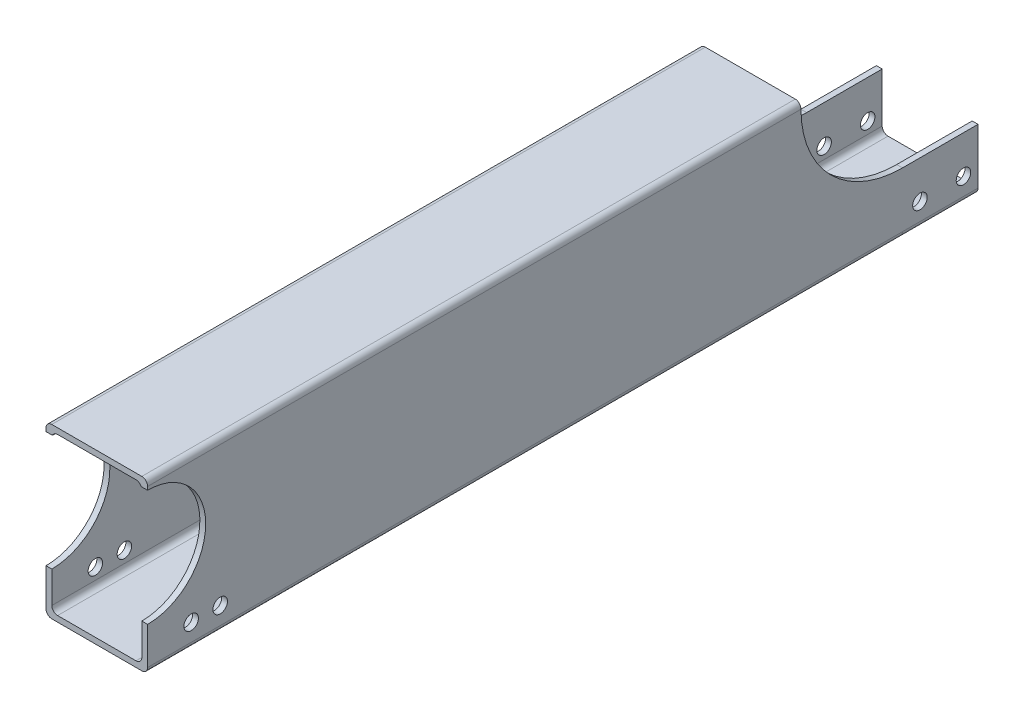
from build123d import *

# Parameters (mm, degrees)
SKETCH1_W      = 35
SKETCH1_H      = 58
SKETCH1_W_2    = 31
SKETCH1_H_2    = 54
EXTRUDE1_DEPTH = 260
FILLET1_R      = 2
SKETCH2_R      = 2.5
EXTRUDE2_DEPTH = 203.8
SKETCH3_R      = 2.5
EXTRUDE3_DEPTH = 10
EXTRUDE5_DEPTH = 26
FILLET6_R      = 2
FILLET7_R      = 2
FILLET8_R      = 2
FILLET9_R      = 2
SKETCH7_R      = 2.5
EXTRUDE6_DEPTH = 36
SKETCH8_R      = 20
SKETCH8_R_2    = 34.977592073
EXTRUDE7_DEPTH = 36


with BuildPart() as part:
    # Sketch1 → Extrude1 (new body)
    with BuildSketch(Plane.XY):
        with Locations((7.633211381, 3.238015245)):
            Rectangle(SKETCH1_W, SKETCH1_H)
        with Locations((7.633211381, 3.238015245)):
            Rectangle(SKETCH1_W_2, SKETCH1_H_2, mode=Mode.SUBTRACT)
    extrude(amount=EXTRUDE1_DEPTH)

    # Fillet1
    fillet1_edges = [part.edges().sort_by_distance(p)[0] for p in [
        (-7.866788619, 30.238015245, 130),
        (-7.866788619, -23.761984755, 130),
        (23.133211381, -23.761984755, 130),
        (23.133211381, 30.238015245, 130),
        (-9.866788619, 32.238015245, 130),
        (25.133211381, 32.238015245, 130),
        (25.133211381, -25.761984755, 130),
        (-9.866788619, -25.761984755, 130),
    ]]
    fillet(fillet1_edges, radius=FILLET1_R)

    # Sketch2 → Extrude2 (cut)
    with BuildSketch(Plane.ZY.offset(9.866788619)):
        with Locations((245, -17.761984755)):
            Circle(SKETCH2_R)
        with Locations((235, -17.761984755)):
            Circle(SKETCH2_R)
    extrude(amount=-EXTRUDE2_DEPTH, mode=Mode.SUBTRACT)

    # Sketch3 → Extrude3 (cut)
    with BuildSketch(Plane.ZY.offset(9.866788619)):
        with Locations((199, -17.761984755)):
            Circle(SKETCH3_R)
    extrude(amount=-EXTRUDE3_DEPTH, mode=Mode.SUBTRACT)

    # Sketch5 → Extrude5 (add)
    with BuildSketch(Plane(origin=(0, 0, 0), x_dir=(-1, 0, 0), z_dir=(0, 0, -1))):
        Polygon((-25.133211381, -4.739576828), (-25.133211381, -23.761984755), (-25.133211381, -25.761984755), (7.866788619, -25.761984755), (9.866788619, -25.761984755), (9.866788619, -4.739576828), (7.866788619, -4.739576828), (7.866788619, -21.761984755), (7.866788619, -23.761984755), (-23.133211381, -23.761984755), (-23.133211381, -4.739576828), align=None)
    extrude(amount=EXTRUDE5_DEPTH)

    # Fillet6
    fillet6_edges = [part.edges().sort_by_distance(p)[0] for p in [
        (25.133211381, -25.761984755, -13),
    ]]
    fillet(fillet6_edges, radius=FILLET6_R)

    # Fillet7
    fillet7_edges = [part.edges().sort_by_distance(p)[0] for p in [
        (-9.866788619, -25.761984755, -13),
    ]]
    fillet(fillet7_edges, radius=FILLET7_R)

    # Fillet8
    fillet8_edges = [part.edges().sort_by_distance(p)[0] for p in [
        (23.133211381, -23.761984755, -13),
    ]]
    fillet(fillet8_edges, radius=FILLET8_R)

    # Fillet9
    fillet9_edges = [part.edges().sort_by_distance(p)[0] for p in [
        (-7.866788619, -23.761984755, -13),
    ]]
    fillet(fillet9_edges, radius=FILLET9_R)

    # Sketch7 → Extrude6 (cut, through all)
    with BuildSketch(Plane.ZY.offset(9.866788619)):
        with Locations((-6, -17.761984755)):
            Circle(SKETCH7_R)
        with Locations((-21, -17.761984755)):
            Circle(SKETCH7_R)
    extrude(amount=-EXTRUDE6_DEPTH, mode=Mode.SUBTRACT)

    # Sketch8 → Extrude7 (cut, through all)
    with BuildSketch(Plane.ZY.offset(9.866788619)):
        with Locations((260, 9.097389033)):
            Circle(SKETCH8_R)
        with Locations((0, 30.238015245)):
            Circle(SKETCH8_R_2)
    extrude(amount=-EXTRUDE7_DEPTH, mode=Mode.SUBTRACT)


solid = part.part
